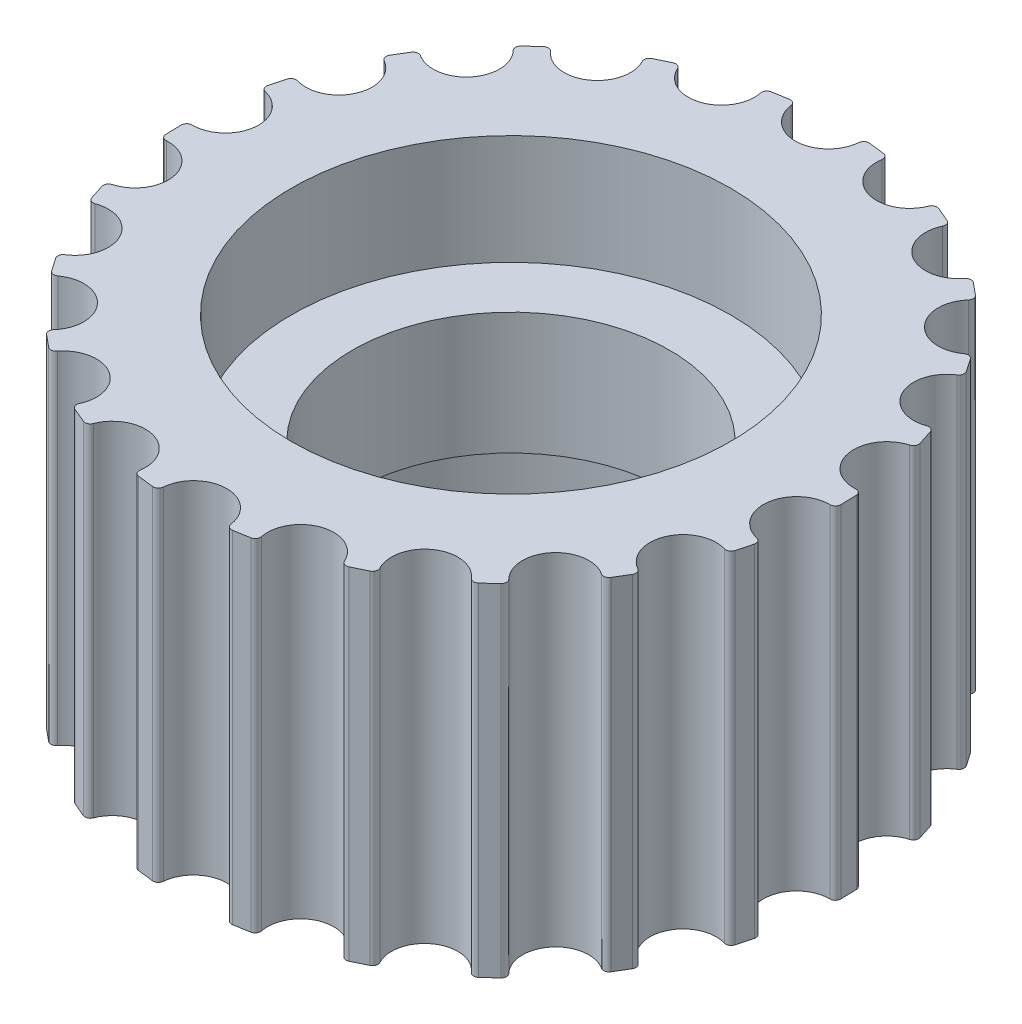
from build123d import *

# Parameters (mm, degrees)
SKETCH2_R           = 4.5
BOSS_EXTRUDE1_DEPTH = 3.5
SKETCH2_3_R         = 4.5
SKETCH2_3_R_2       = 3.25
BOSS_EXTRUDE2_DEPTH = 1.25


with BuildPart() as part:
    # Sketch2 → Boss-Extrude1 (new, symmetric)
    with BuildSketch(Plane(origin=(0, 0, 0), x_dir=(1, 0, 0), z_dir=(0, 1, 0))):
        with BuildLine():
            Line((-0.973020228, 6.679500852), (-1.292919007, 6.625017769))
            ThreePointArc((-1.292919007, 6.625017769), (-1.363353555, 6.578096432), (-1.379618663, 6.495041729))
            ThreePointArc((-1.379618663, 6.495041729), (-1.837581239, 5.71163958), (-2.666453991, 6.080988477))
            ThreePointArc((-2.666453991, 6.080988477), (-2.729363352, 6.139440769), (-2.815114904, 6.134865902))
            Line((-2.815114904, 6.134865902), (-3.106705876, 5.992463865))
            ThreePointArc((-3.106705876, 5.992463865), (-3.161068061, 5.927599467), (-3.153275104, 5.843326652))
            ThreePointArc((-3.153275104, 5.843326652), (-3.371977088, 4.962634828), (-4.271332279, 5.083502059))
            ThreePointArc((-4.271332279, 5.083502059), (-4.348161282, 5.121863008), (-4.429150404, 5.093314451))
            Line((-4.429150404, 5.093314451), (-4.668810603, 4.874530027))
            ThreePointArc((-4.668810603, 4.874530027), (-4.702696325, 4.796977495), (-4.671476642, 4.718313851))
            ThreePointArc((-4.671476642, 4.718313851), (-4.633200099, 3.811680765), (-5.53017732, 3.674274387))
            ThreePointArc((-5.53017732, 3.674274387), (-5.614701737, 3.689436216), (-5.684367172, 3.639226803))
            Line((-5.684367172, 3.639226803), (-5.852680755, 3.361784605))
            ThreePointArc((-5.852680755, 3.361784605), (-5.863344793, 3.277826785), (-5.811227618, 3.211145173))
            ThreePointArc((-5.811227618, 3.211145173), (-5.519073486, 2.352020845), (-6.341004977, 1.967472704))
            ThreePointArc((-6.341004977, 1.967472704), (-6.426377141, 1.958207093), (-6.479075011, 1.890404493))
            Line((-6.479075011, 1.890404493), (-6.562406211, 1.576781238))
            ThreePointArc((-6.562406211, 1.576781238), (-6.54898463, 1.493219892), (-6.480192185, 1.443922459))
            ThreePointArc((-6.480192185, 1.443922459), (-5.957829055, 0.701908033), (-6.638126814, 0.101371934))
            ThreePointArc((-6.638126814, 0.101371934), (-6.717430382, 0.068429527), (-6.748891418, -0.011473297))
            Line((-6.748891418, -0.011473297), (-6.740489237, -0.335869719))
            ThreePointArc((-6.740489237, -0.335869719), (-6.704069372, -0.412264947), (-6.624174813, -0.440184416))
            ThreePointArc((-6.624174813, -0.440184416), (-5.913921439, -1.004975343), (-6.397471788, -1.772847538))
            ThreePointArc((-6.397471788, -1.772847538), (-6.464282055, -1.826797943), (-6.471957472, -1.912327739))
            Line((-6.471957472, -1.912327739), (-6.372502605, -2.221216659))
            ThreePointArc((-6.372502605, -2.221216659), (-6.316034978, -2.284256682), (-6.231510886, -2.288536318))
            ThreePointArc((-6.231510886, -2.288536318), (-5.390907771, -2.630347745), (-5.638536337, -3.503347597))
            ThreePointArc((-5.638536337, -3.503347597), (-5.687440734, -3.573935259), (-5.670708714, -3.658162912))
            Line((-5.670708714, -3.658162912), (-5.488258403, -3.926519986))
            ThreePointArc((-5.488258403, -3.926519986), (-5.416317684, -3.971097676), (-5.334011699, -3.951390768))
            ThreePointArc((-5.334011699, -3.951390768), (-4.43115951, -4.042531166), (-4.422804899, -4.949933419))
            ThreePointArc((-4.422804899, -4.949933419), (-4.449841481, -5.031439745), (-4.410057553, -5.107541632))
            Line((-4.410057553, -5.107541632), (-4.159392837, -5.313626166))
            ThreePointArc((-4.159392837, -5.313626166), (-4.077807237, -5.336130104), (-4.0043873, -5.294033189))
            ThreePointArc((-4.0043873, -5.294033189), (-3.112429751, -5.127118905), (-2.848768804, -5.995411224))
            ThreePointArc((-2.848768804, -5.995411224), (-2.851747229, -6.081233058), (-2.79213445, -6.143043855))
            Line((-2.79213445, -6.143043855), (-2.493562694, -6.270160106))
            ThreePointArc((-2.493562694, -6.270160106), (-2.408941792, -6.268767157), (-2.35035595, -6.207690676))
            ThreePointArc((-2.35035595, -6.207690676), (-1.541554137, -5.796244112), (-1.043947095, -6.555082619))
            ThreePointArc((-1.043947095, -6.555082619), (-1.022626068, -6.638267184), (-0.948013912, -6.68077935))
            Line((-0.948013912, -6.68077935), (-0.625723623, -6.718629115))
            ThreePointArc((-0.625723623, -6.718629115), (-0.544922901, -6.693452127), (-0.505917431, -6.618344134))
            ThreePointArc((-0.505917431, -6.618344134), (0.154204334, -5.995698244), (0.845444307, -6.583606355))
            ThreePointArc((0.845444307, -6.583606355), (0.889337482, -6.657414534), (0.972904383, -6.677183984))
            Line((0.972904383, -6.677183984), (1.292803162, -6.622700901))
            ThreePointArc((1.292803162, -6.622700901), (1.363237709, -6.575779564), (1.379502817, -6.492724861))
            ThreePointArc((1.379502817, -6.492724861), (1.837465393, -5.709322713), (2.666338146, -6.078671609))
            ThreePointArc((2.666338146, -6.078671609), (2.729247506, -6.137123901), (2.814999058, -6.132549034))
            Line((2.814999058, -6.132549034), (3.10659003, -5.990146997))
            ThreePointArc((3.10659003, -5.990146997), (3.160952215, -5.925282599), (3.153159258, -5.841009785))
            ThreePointArc((3.153159258, -5.841009785), (3.371861242, -4.96031796), (4.271216433, -5.081185191))
            ThreePointArc((4.271216433, -5.081185191), (4.348045436, -5.11954614), (4.429034558, -5.090997583))
            Line((4.429034558, -5.090997583), (4.668694758, -4.872213159))
            ThreePointArc((4.668694758, -4.872213159), (4.702580479, -4.794660627), (4.671360797, -4.715996984))
            ThreePointArc((4.671360797, -4.715996984), (4.633084254, -3.809363897), (5.530061474, -3.671957519))
            ThreePointArc((5.530061474, -3.671957519), (5.614585891, -3.687119348), (5.684251327, -3.636909935))
            Line((5.684251327, -3.636909935), (5.852564909, -3.359467737))
            ThreePointArc((5.852564909, -3.359467737), (5.863228948, -3.275509917), (5.811111772, -3.208828305))
            ThreePointArc((5.811111772, -3.208828305), (5.51895764, -2.349703977), (6.340889131, -1.965155837))
            ThreePointArc((6.340889131, -1.965155837), (6.426261296, -1.955890225), (6.478959166, -1.888087625))
            Line((6.478959166, -1.888087625), (6.562290365, -1.57446437))
            ThreePointArc((6.562290365, -1.57446437), (6.548868784, -1.490903024), (6.480076339, -1.441605591))
            ThreePointArc((6.480076339, -1.441605591), (5.957713209, -0.699591165), (6.638010968, -0.099055066))
            ThreePointArc((6.638010968, -0.099055066), (6.717314536, -0.066112659), (6.748775572, 0.013790165))
            Line((6.748775572, 0.013790165), (6.740373391, 0.338186587))
            ThreePointArc((6.740373391, 0.338186587), (6.703953527, 0.414581815), (6.624058967, 0.442501284))
            ThreePointArc((6.624058967, 0.442501284), (5.913805593, 1.007292211), (6.397355942, 1.775164406))
            ThreePointArc((6.397355942, 1.775164406), (6.46416621, 1.829114811), (6.471841626, 1.914644607))
            Line((6.471841626, 1.914644607), (6.372386759, 2.223533527))
            ThreePointArc((6.372386759, 2.223533527), (6.315919132, 2.28657355), (6.23139504, 2.290853186))
            ThreePointArc((6.23139504, 2.290853186), (5.390791926, 2.632664613), (5.638420492, 3.505664465))
            ThreePointArc((5.638420492, 3.505664465), (5.687324888, 3.576252127), (5.670592868, 3.66047978))
            Line((5.670592868, 3.66047978), (5.488142557, 3.928836854))
            ThreePointArc((5.488142557, 3.928836854), (5.416201839, 3.973414544), (5.333895854, 3.953707636))
            ThreePointArc((5.333895854, 3.953707636), (4.431043665, 4.044848034), (4.422689053, 4.952250287))
            ThreePointArc((4.422689053, 4.952250287), (4.449725636, 5.033756613), (4.409941708, 5.1098585))
            Line((4.409941708, 5.1098585), (4.159276992, 5.315943034))
            ThreePointArc((4.159276992, 5.315943034), (4.077691391, 5.338446972), (4.004271455, 5.296350057))
            ThreePointArc((4.004271455, 5.296350057), (3.112313906, 5.129435773), (2.848652958, 5.997728092))
            ThreePointArc((2.848652958, 5.997728092), (2.851631383, 6.083549925), (2.792018605, 6.145360723))
            Line((2.792018605, 6.145360723), (2.493446848, 6.272476974))
            ThreePointArc((2.493446848, 6.272476974), (2.408825946, 6.271084025), (2.350240104, 6.210007544))
            ThreePointArc((2.350240104, 6.210007544), (1.541438291, 5.79856098), (1.043831249, 6.557399487))
            ThreePointArc((1.043831249, 6.557399487), (1.022510223, 6.640584052), (0.947898066, 6.683096218))
            Line((0.947898066, 6.683096218), (0.625607777, 6.720945983))
            ThreePointArc((0.625607777, 6.720945983), (0.544807056, 6.695768995), (0.505801585, 6.620661002))
            ThreePointArc((0.505801585, 6.620661002), (-0.154320179, 5.998015112), (-0.845560152, 6.585923223))
            ThreePointArc((-0.845560152, 6.585923223), (-0.889453328, 6.659731402), (-0.973020228, 6.679500852))
        make_face()
        Circle(SKETCH2_R, mode=Mode.SUBTRACT)
    extrude(amount=BOSS_EXTRUDE1_DEPTH, both=True)

    # Sketch2_3 → Boss-Extrude2 (add, symmetric)
    with BuildSketch(Plane(origin=(0, 0, 0), x_dir=(1, 0, 0), z_dir=(0, 1, 0))):
        Circle(SKETCH2_3_R)
        Circle(SKETCH2_3_R_2, mode=Mode.SUBTRACT)
    extrude(amount=BOSS_EXTRUDE2_DEPTH, both=True)


solid = part.part
